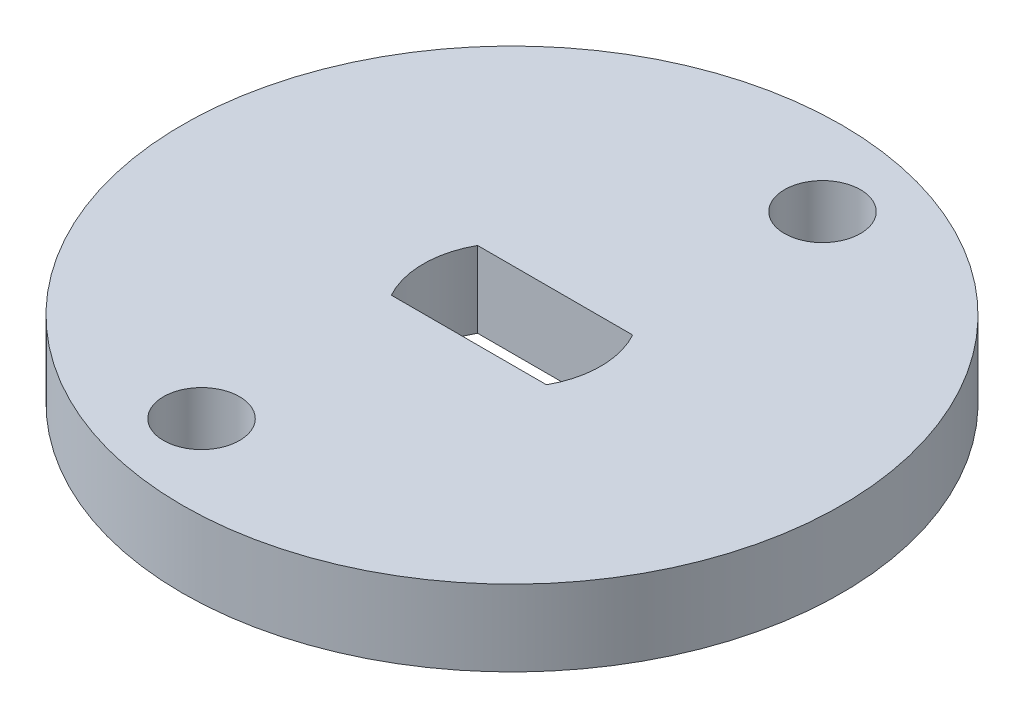
from build123d import *

# Parameters (mm, degrees)
SKETCH1_R           = 13
SKETCH1_R_2         = 1.5
BOSS_EXTRUDE1_DEPTH = 3


with BuildPart() as part:
    # Sketch1 → Boss-Extrude1 (new body)
    with BuildSketch(Plane(origin=(0, 0, 0), x_dir=(1, 0, 0), z_dir=(0, 1, 0))):
        Circle(SKETCH1_R)
        with Locations((-2.588190451, -9.659258263)):
            Circle(SKETCH1_R_2, mode=Mode.SUBTRACT)
        with Locations((2.588190451, 9.659258263)):
            Circle(SKETCH1_R_2, mode=Mode.SUBTRACT)
        with BuildLine():
            Line((-3.059411708, 1.7), (3.059411708, 1.7))
            ThreePointArc((3.059411708, 1.7), (3.5, 0), (3.059411708, -1.7))
            Line((3.059411708, -1.7), (-3.059411708, -1.7))
            ThreePointArc((-3.059411708, -1.7), (-3.5, 0), (-3.059411708, 1.7))
        make_face(mode=Mode.SUBTRACT)
    extrude(amount=BOSS_EXTRUDE1_DEPTH)


solid = part.part
